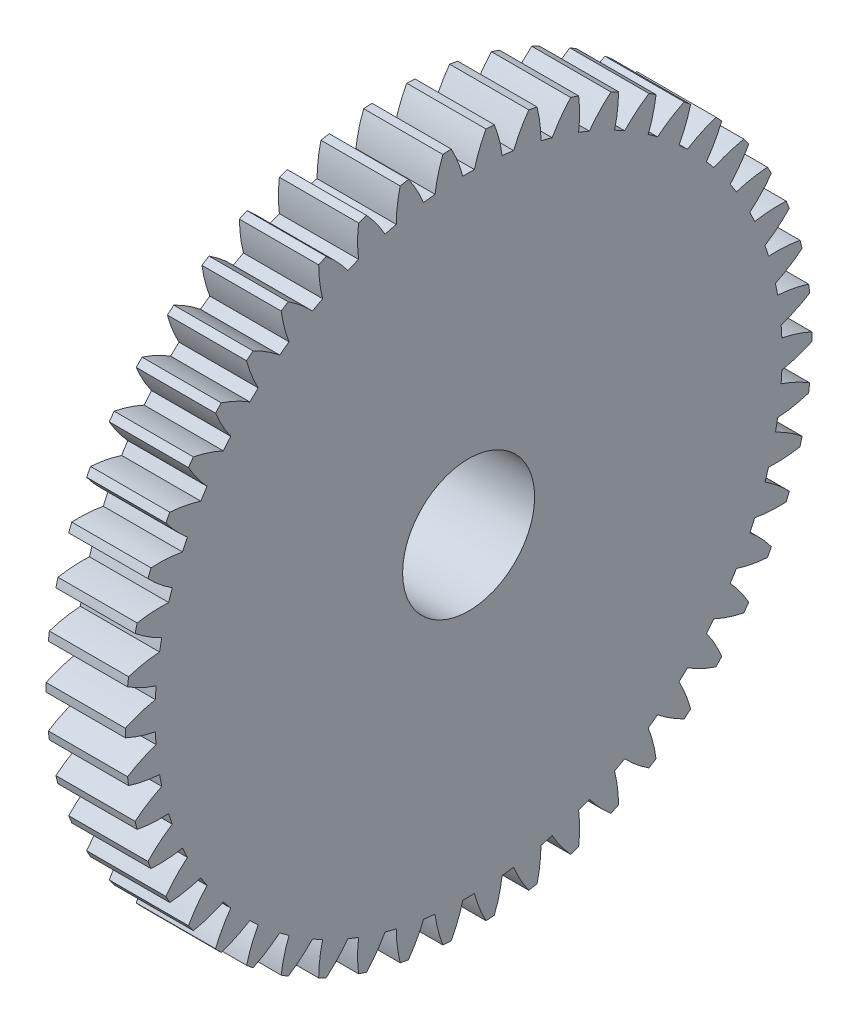
from build123d import *

# Parameters (mm, degrees)
BASPROSKE_W      = 3
BASPROSKE_H      = 13
TOOTHCUT_DEPTH   = 19.62793601
TEETHCUTS_COUNT  = 50
TEETHCUTS_ANGLE  = 352.8
HUBNEAONESKE_R   = 4.5
HUBNEARONE_DEPTH = 5.0000508
BORSKE_R         = 2.5
BORE_DEPTH       = 8.0000508


with BuildPart() as part:
    # BasProSke → Base-Revolve (revolve)
    with BuildSketch(Plane(origin=(0, 0, 0), x_dir=(1, 0, 0), z_dir=(0, 1, 0)), mode=Mode.PRIVATE) as base_revolve_sk:
        with Locations((1.5, 6.5)):
            Rectangle(BASPROSKE_W, BASPROSKE_H)
    revolve(base_revolve_sk.sketch.rotate(Axis((-10, 0, 0), (1, 0, 0)), 180), axis=Axis((-10, 0, 0), (1, 0, 0)))

    # TooCutSke → ToothCut (cut, through all)
    with BuildSketch(Plane(origin=(0, 0, 0), x_dir=(0, 0, -1), z_dir=(1, 0, 0))):
        with BuildLine():
            ThreePointArc((0.218701072, 11.871985758), (0, 11.874), (-0.218701072, 11.871985758))
            ThreePointArc((-0.218701072, 11.871985758), (-0.410224227, 12.453928998), (-0.671481128, 13.008080498))
            ThreePointArc((-0.671481128, 13.008080498), (0, 13.0254), (0.671481128, 13.008080498))
            ThreePointArc((0.671481128, 13.008080498), (0.410224227, 12.453928998), (0.218701072, 11.871985758))
        make_face()
    toothcut = extrude(amount=TOOTHCUT_DEPTH, mode=Mode.SUBTRACT)

    # TeethCuts: ToothCut ×50 about axis
    teethcuts_axis = Axis((-10, 0, 0), (1, 0, 0))
    for i in range(1, TEETHCUTS_COUNT):
        add(toothcut.rotate(teethcuts_axis, i * TEETHCUTS_ANGLE / (TEETHCUTS_COUNT - 1)), mode=Mode.SUBTRACT)

    # HubNeaOneSke → HubNearOne (add)
    with BuildSketch(Plane.ZY):
        with Locations(Location((0, 0, 0), (0, 0, 180))):
            Circle(HUBNEAONESKE_R)
    extrude(amount=HUBNEARONE_DEPTH)

    # BorSke → Bore (cut, symmetric)
    with BuildSketch(Plane(origin=(0, 0, 0), x_dir=(0, 0, -1), z_dir=(1, 0, 0))):
        with Locations(Location((0, 0, 0), (0, 0, 180))):
            Circle(BORSKE_R)
    extrude(amount=BORE_DEPTH, both=True, mode=Mode.SUBTRACT)


solid = part.part
